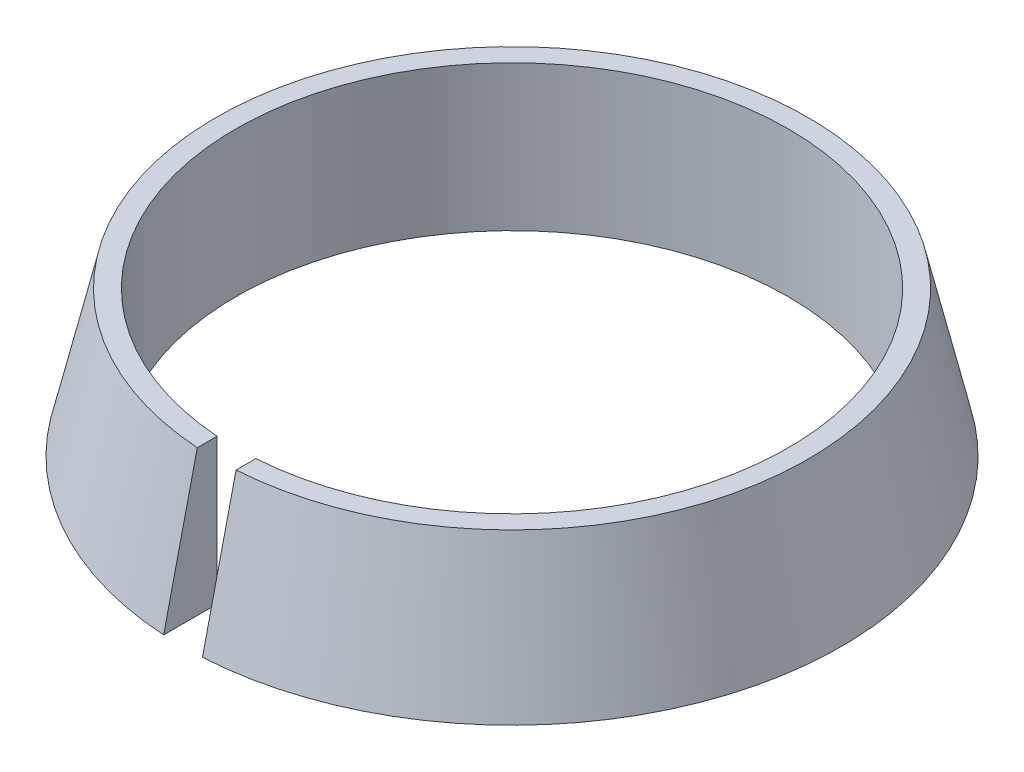
from build123d import *

# Parameters (mm, degrees)
ESQUISSE2_W             = 2
ESQUISSE2_H             = 7.5
ENL_V_MAT_EXTRU_4_DEPTH = 18


with BuildPart() as part:
    # Esquisse1 → Révolution1 (revolve)
    with BuildSketch(Plane.XY, mode=Mode.PRIVATE) as r_volution1_sk:
        Polygon((14.25, 0), (14.25, 7.5), (15.268488567, 7.5), (17, 0), align=None)
    revolve(r_volution1_sk.sketch.rotate(Axis((0, -11.232892416, 0), (0, 1, 0)), 90), axis=Axis((0, -11.232892416, 0), (0, 1, 0)))  # turned: the seam where the file's is

    # Esquisse2 → Enlèv. mat.-Extru.4 (cut, through all)
    with BuildSketch(Plane.XY):
        with Locations((0, 3.75)):
            Rectangle(ESQUISSE2_W, ESQUISSE2_H)
    extrude(amount=ENL_V_MAT_EXTRU_4_DEPTH, mode=Mode.SUBTRACT)


solid = part.part
